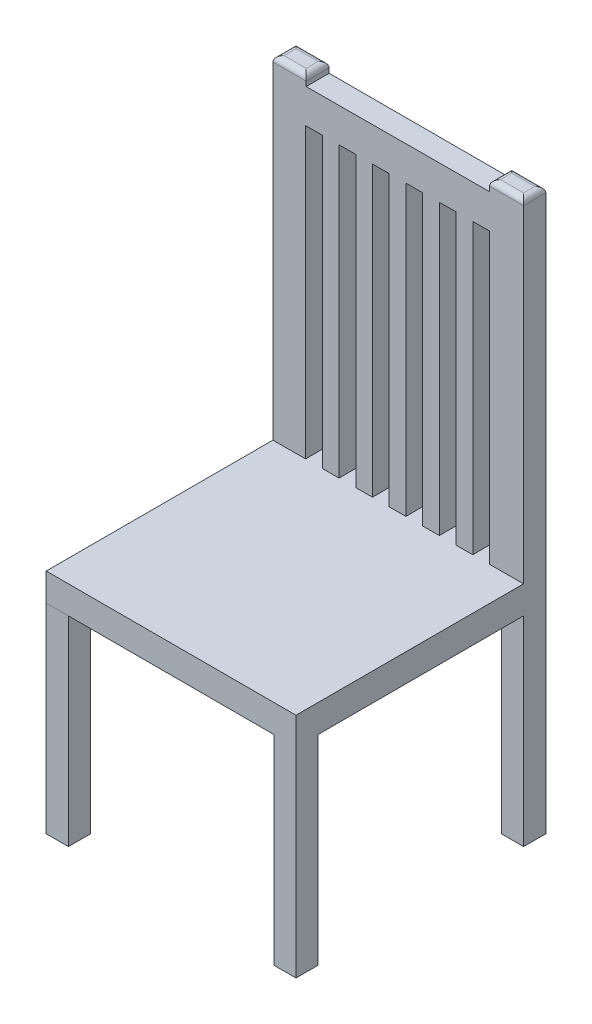
from build123d import *

# Parameters (mm, degrees)
SKETCH1_W           = 450
SKETCH1_H           = 450
BOSS_EXTRUDE1_DEPTH = 50
SKETCH2_W           = 40
SKETCH2_H           = 40
BOSS_EXTRUDE2_DEPTH = 360
BOSS_EXTRUDE3_DEPTH = 600
SKETCH4_W           = 30
SKETCH4_H           = 520
CUT_EXTRUDE2_DEPTH  = 300
FILLET2_R           = 10
FILLET4_R           = 10


with BuildPart() as part:
    # Sketch1 → Boss-Extrude1 (new body)
    with BuildSketch(Plane(origin=(0, 0, 0), x_dir=(1, 0, 0), z_dir=(0, 1, 0))):
        Rectangle(SKETCH1_W, SKETCH1_H)
    extrude(amount=BOSS_EXTRUDE1_DEPTH)

    # Sketch2 → Boss-Extrude2 (add)
    with BuildSketch(Plane(origin=(0, 0, 0), x_dir=(-1, 0, 0), z_dir=(0, -1, 0))):
        Polygon((225, -225), (185.000000233, -225.004313347), (185.000000057, -185.004313347), (225, -185.002182787), align=None)
        Polygon((185.000923636, 225), (185, 185.000000011), (225, 185.000000011), (225, 225), align=None)
        with Locations((-205, 205)):
            Rectangle(SKETCH2_W, SKETCH2_H)
        with Locations((-205, -205)):
            Rectangle(SKETCH2_W, SKETCH2_H)
    extrude(amount=BOSS_EXTRUDE2_DEPTH)

    # Sketch3 → Boss-Extrude3 (add)
    with BuildSketch(Plane(origin=(0, 50, 0), x_dir=(1, 0, 0), z_dir=(0, 1, 0))):
        Polygon((-225, 225), (-225, 183.319526978), (225, 185.000000043), (225, 225), align=None)
    extrude(amount=BOSS_EXTRUDE3_DEPTH)

    # Sketch4 → Cut-Extrude2 (cut, symmetric)
    with BuildSketch(Plane(origin=(-0.687713792, 0, -184.157195323), x_dir=(0.999993027, 0, -0.003734359), z_dir=(0.003734359, 0, 0.999993027))):
        with Locations((-150.5, 310)):
            Rectangle(SKETCH4_W, SKETCH4_H)
        with Locations((89.5, 310)):
            Rectangle(SKETCH4_W, SKETCH4_H)
        with Locations((-90.5, 310)):
            Rectangle(SKETCH4_W, SKETCH4_H)
        with Locations((-30.5, 310)):
            Rectangle(SKETCH4_W, SKETCH4_H)
        with Locations((149.5, 310)):
            Rectangle(SKETCH4_W, SKETCH4_H)
        with Locations((29.5, 310)):
            Rectangle(SKETCH4_W, SKETCH4_H)
        Polygon((-164.5, 631.432523358), (164.5, 631.432523358), (164.5, 652.515401433), (-164.5, 650), align=None)
    extrude(amount=CUT_EXTRUDE2_DEPTH, both=True, mode=Mode.SUBTRACT)

    # Fillet2
    fillet2_edges = [part.edges().sort_by_distance(p)[0] for p in [
        (194.330455246, 650, -225),
        (225, 650, -205.000000022),
        (194.405569596, 650, -184.885748674),
        (163.736024842, 650, -204.885748652),
    ]]
    fillet(fillet2_edges, radius=FILLET2_R)

    # Fillet4
    fillet4_edges = [part.edges().sort_by_distance(p)[0] for p in [
        (-225, 650, -204.159763489),
        (-195.093283388, 650, -183.43121016),
        (-195.170691778, 650, -225),
        (-165.263975166, 650, -204.271446671),
    ]]
    fillet(fillet4_edges, radius=FILLET4_R)


solid = part.part
